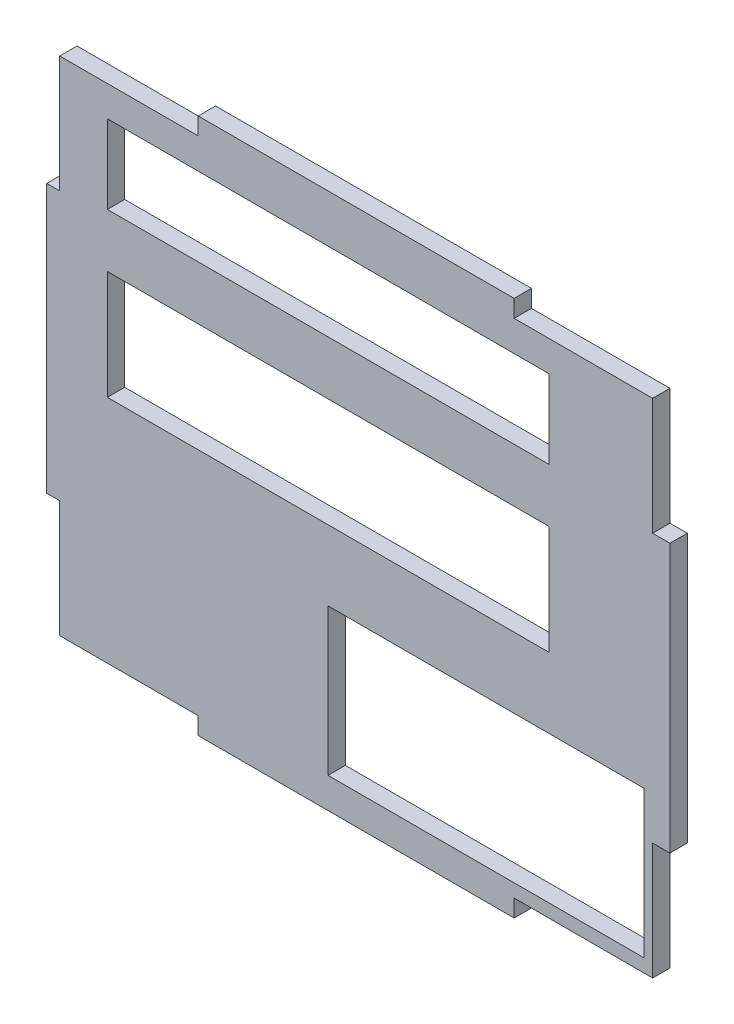
from build123d import *

# Parameters (mm, degrees)
SKETCH_1_W          = 72
SKETCH_1_H          = 62
EXTRUDE_1_DEPTH     = 2
SKETCH_2_W          = 18
SKETCH_2_H          = 2
CUT_EXTRUDE_1_DEPTH = 3
SKETCH_3_W          = 2
SKETCH_3_H          = 15.5
CUT_EXTRUDE_2_DEPTH = 3
SKETCH_4_W          = 36.5
SKETCH_4_H          = 16.955544823
SKETCH_4_W_2        = 51
SKETCH_4_H_2        = 12.596379679
SKETCH_4_H_3        = 9.075045386
CUT_EXTRUDE_3_DEPTH = 3


with BuildPart() as part:
    # ｽｹｯﾁ1 → ﾎﾞｽ - 押し出し1 (new body)
    with BuildSketch(Plane.XY):
        with Locations((-1.042641223, 9.736263736)):
            Rectangle(SKETCH_1_W, SKETCH_1_H)
    extrude(amount=EXTRUDE_1_DEPTH)

    # ｽｹｯﾁ2 → ｶｯﾄ - 押し出し1 (cut, through all)
    with BuildSketch(Plane.XY.offset(2)):
        with Locations((25.957358777, 39.736263736)):
            Rectangle(SKETCH_2_W, SKETCH_2_H)
        with Locations((-28.542641223, 39.736263736)):
            Rectangle(SKETCH_2_W, SKETCH_2_H)
        with Locations((-28.542641223, -20.263736264)):
            Rectangle(SKETCH_2_W, SKETCH_2_H)
        with Locations((25.957358777, -20.263736264)):
            Rectangle(SKETCH_2_W, SKETCH_2_H)
    extrude(amount=-CUT_EXTRUDE_1_DEPTH, mode=Mode.SUBTRACT)

    # ｽｹｯﾁ3 → ｶｯﾄ - 押し出し2 (cut, through all)
    with BuildSketch(Plane.XY.offset(2)):
        with Locations((33.957358777, 32.986263736)):
            Rectangle(SKETCH_3_W, SKETCH_3_H)
        with Locations((33.957358777, -13.513736264)):
            Rectangle(SKETCH_3_W, SKETCH_3_H)
        with Locations((-36.542641223, -13.513736264)):
            Rectangle(SKETCH_3_W, SKETCH_3_H)
        with Locations((-36.542641223, 32.986263736)):
            Rectangle(SKETCH_3_W, SKETCH_3_H)
    extrude(amount=-CUT_EXTRUDE_2_DEPTH, mode=Mode.SUBTRACT)

    # ｽｹｯﾁ4 → ｶｯﾄ - 押し出し3 (cut, through all)
    with BuildSketch(Plane.XY.offset(2)):
        with Locations((13.707358777, -9.261963853)):
            Rectangle(SKETCH_4_W, SKETCH_4_H)
        with Locations((-4.542641223, 13.634453576)):
            Rectangle(SKETCH_4_W_2, SKETCH_4_H_2)
        with Locations((-4.542641223, 30.673786429)):
            Rectangle(SKETCH_4_W_2, SKETCH_4_H_3)
    extrude(amount=-CUT_EXTRUDE_3_DEPTH, mode=Mode.SUBTRACT)


solid = part.part
